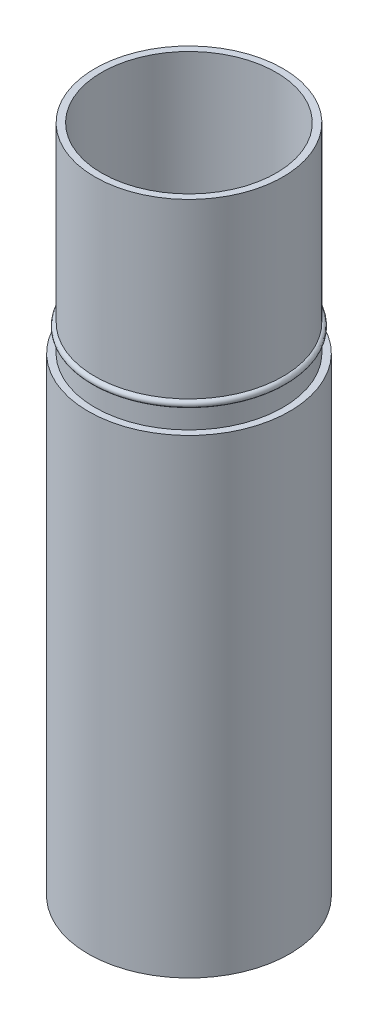
from build123d import *

# Parameters (mm, degrees)
SKETCH1_R           = 15
BOSS_EXTRUDE1_DEPTH = 70
SKETCH2_R           = 14
BOSS_EXTRUDE2_DEPTH = 16
SKETCH3_R           = 0.5
SKETCH4_R           = 13
CUT_EXTRUDE1_DEPTH  = 78
SKETCH5_R           = 2
CUT_EXTRUDE2_DEPTH  = 9
SKETCH6_W           = 1
SKETCH6_H           = 0.792029488
BOSS_EXTRUDE3_DEPTH = 75
CIRPATTERN1_COUNT   = 3
SKETCH7_R           = 14
CUT_EXTRUDE3_DEPTH  = 5
SCALE1_SCALE        = 0.655
SKETCH8_R           = 9.17
SKETCH8_R_2         = 8.515
BOSS_EXTRUDE4_DEPTH = 9


with BuildPart() as part:
    # Sketch1 → Boss-Extrude1 (new body)
    with BuildSketch(Plane(origin=(0, 0, 0), x_dir=(1, 0, 0), z_dir=(0, 1, 0))):
        Circle(SKETCH1_R)
    extrude(amount=BOSS_EXTRUDE1_DEPTH)

    # Sketch2 → Boss-Extrude2 (add)
    with BuildSketch(Plane(origin=(0, 70, 0), x_dir=(1, 0, 0), z_dir=(0, 1, 0))):
        Circle(SKETCH2_R)
    extrude(amount=BOSS_EXTRUDE2_DEPTH)

    # Sketch3 → Revolve1 (revolve)
    with BuildSketch(Plane.XY):
        with Locations((-14, 73.5)):
            Circle(SKETCH3_R)
    revolve(axis=Axis((0, 70, 0), (0, 1, 0)))

    # Sketch4 → Cut-Extrude1 (cut)
    with BuildSketch(Plane(origin=(0, 86, 0), x_dir=(1, 0, 0), z_dir=(0, 1, 0))):
        Circle(SKETCH4_R)
    extrude(amount=-CUT_EXTRUDE1_DEPTH, mode=Mode.SUBTRACT)

    # Sketch5 → Cut-Extrude2 (cut, through all)
    with BuildSketch(Plane(origin=(0, 8, 0), x_dir=(1, 0, 0), z_dir=(0, 1, 0))):
        Circle(SKETCH5_R)
    extrude(amount=-CUT_EXTRUDE2_DEPTH, mode=Mode.SUBTRACT)

    # Sketch6 → Boss-Extrude3 (add)
    with BuildSketch(Plane(origin=(0, 8, 0), x_dir=(1, 0, 0), z_dir=(0, 1, 0))):
        with Locations((0, 12.896014744)):
            Rectangle(SKETCH6_W, SKETCH6_H)
    boss_extrude3 = extrude(amount=BOSS_EXTRUDE3_DEPTH)

    # CirPattern1: Boss-Extrude3 ×3 about axis
    cirpattern1_axis = Axis((0, 0, 0), (0, 1, 0))
    for i in range(1, CIRPATTERN1_COUNT):
        add(boss_extrude3.rotate(cirpattern1_axis, i * 360 / CIRPATTERN1_COUNT))

    # Sketch7 → Cut-Extrude3 (cut)
    with BuildSketch(Plane.XZ):
        Circle(SKETCH7_R)
    extrude(amount=-CUT_EXTRUDE3_DEPTH, mode=Mode.SUBTRACT)


with BuildPart() as part_1:
    # Scale1: scaled about (0, 0, 0)
    add(part.part.scale(SCALE1_SCALE))

    # Sketch8 → Boss-Extrude4 (add)
    with BuildSketch(Plane(origin=(0, 56.33, 0), x_dir=(1, 0, 0), z_dir=(0, 1, 0))):
        Circle(SKETCH8_R)
        Circle(SKETCH8_R_2, mode=Mode.SUBTRACT)
    extrude(amount=BOSS_EXTRUDE4_DEPTH)


solid = part_1.part
